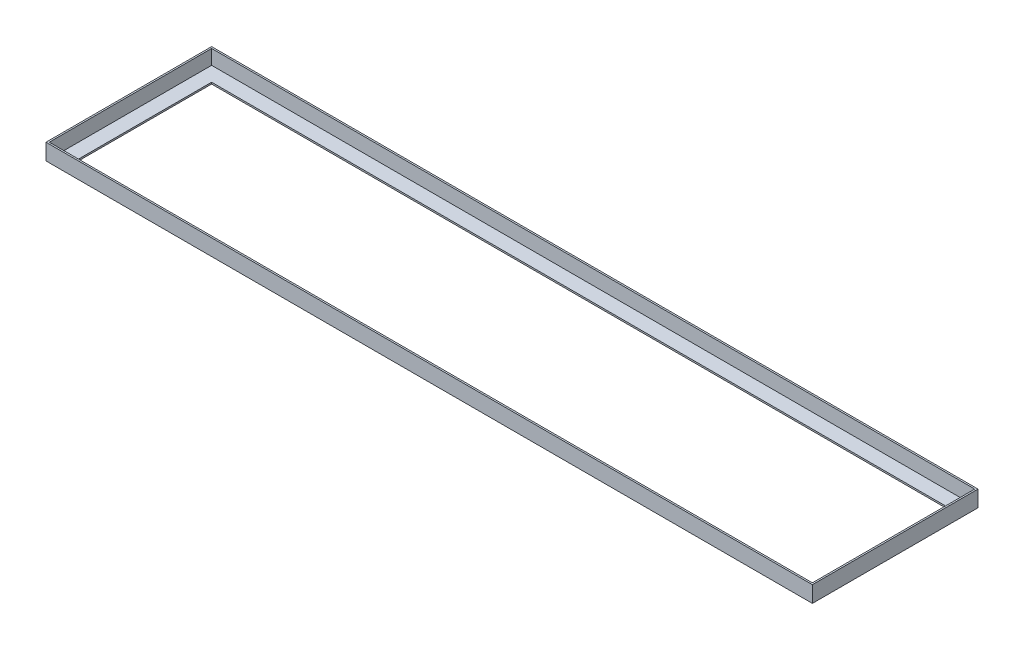
from build123d import *

# Parameters (mm, degrees)
SKETCH1_W           = 944
SKETCH1_H           = 20
BOSS_EXTRUDE1_DEPTH = 204
CUT_EXTRUDE1_DEPTH  = 18
CUT_EXTRUDE2_DEPTH  = 2


with BuildPart() as part:
    # Sketch1 → Boss-Extrude1 (new body)
    with BuildSketch(Plane.XY):
        with Locations((393.099899989, 5.665003505)):
            Rectangle(SKETCH1_W, SKETCH1_H)
    extrude(amount=-BOSS_EXTRUDE1_DEPTH)

    # 3DSketch1 → Cut-Extrude1 (cut)
    with BuildSketch(Plane(origin=(863.099899989, 15.665003505, -202), x_dir=(-0.9781059289848355, 0, 0.2081076444648586), z_dir=(0, -1, 0))):
        Polygon((0, 0), (919.419573246, 195.621185797), (961.041102139, 0), (41.621528893, -195.621185797), align=None)
    extrude(amount=CUT_EXTRUDE1_DEPTH, mode=Mode.SUBTRACT)

    # 3DSketch2 → Cut-Extrude2 (cut)
    with BuildSketch(Plane(origin=(-58.900100011, -2.334996495, -184), x_dir=(0.9839394949368245, 0, 0.1785022977540257), z_dir=(0, -1, 0))):
        Polygon((0, 0), (889.481303423, -161.36607717), (918.755680255, 0), (29.274376832, 161.36607717), align=None)
    extrude(amount=CUT_EXTRUDE2_DEPTH, mode=Mode.SUBTRACT)


solid = part.part
